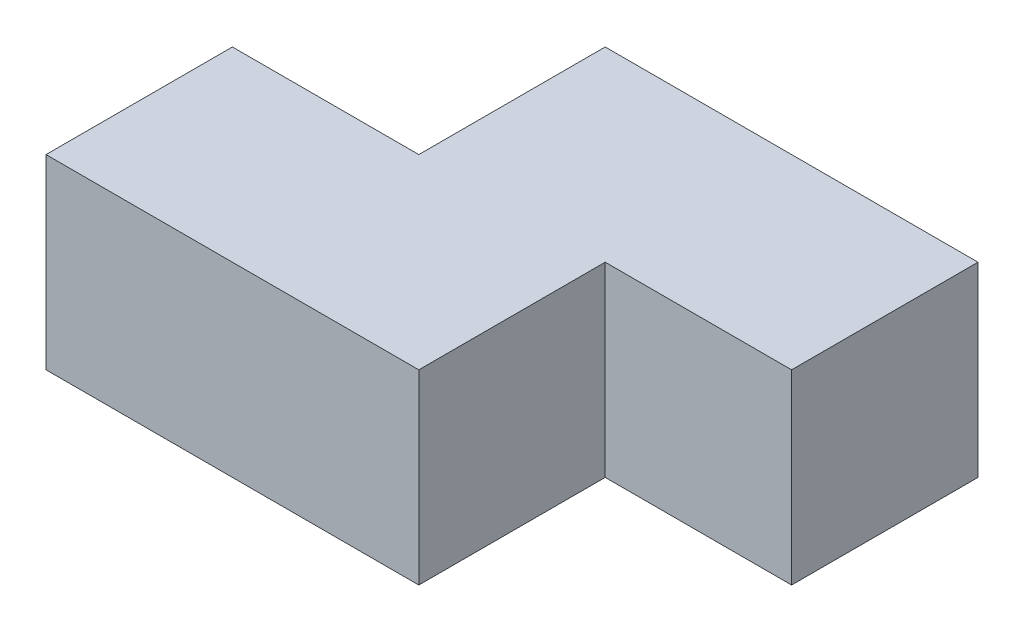
from build123d import *

# Parameters (mm, degrees)
SALIENTE_EXTRUIR1_DEPTH = 200


with BuildPart() as part:
    # Croquis1 → Saliente-Extruir1 (new body)
    with BuildSketch(Plane(origin=(0, 0, 0), x_dir=(1, 0, 0), z_dir=(0, 1, 0))):
        Polygon((0, 0), (400, 0), (400, 200), (600, 200), (600, 400), (200, 400), (200, 200), (0, 200), align=None)
    extrude(amount=SALIENTE_EXTRUIR1_DEPTH)


solid = part.part
